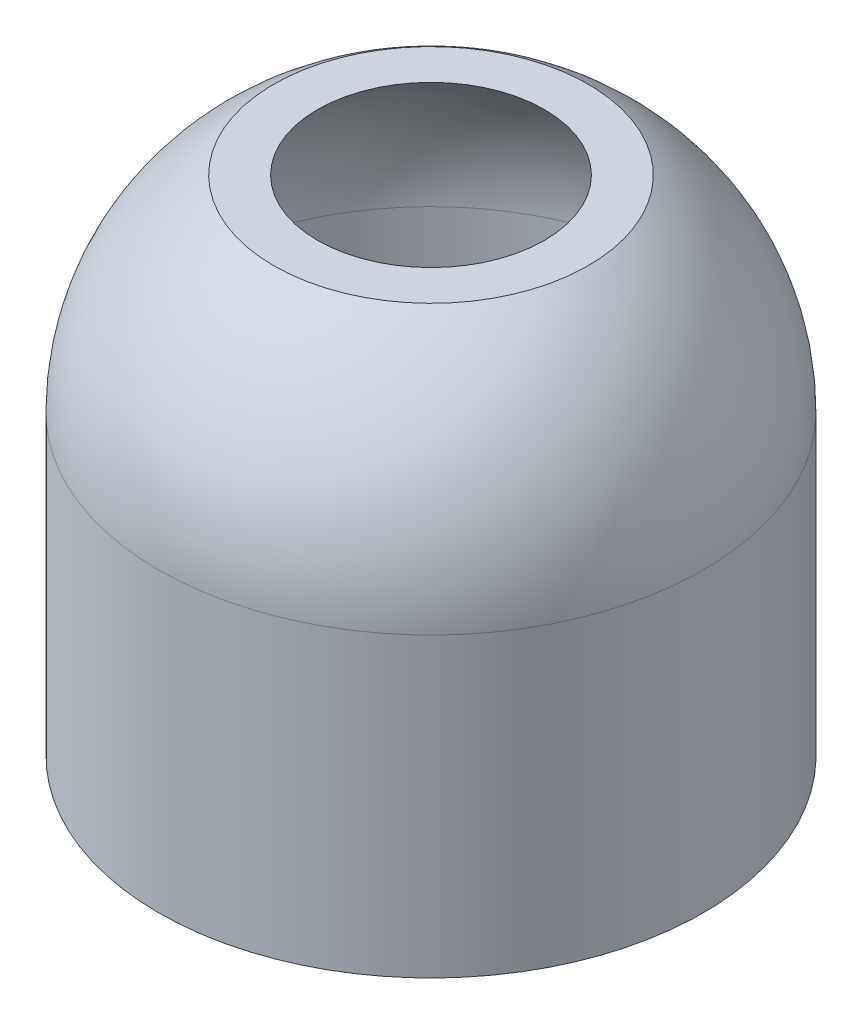
from build123d import *


with BuildPart() as part:
    # Sketch3 → Revolve1 (revolve)
    with BuildSketch(Plane.XY):
        with BuildLine():
            Line((27.5, 0), (27.5, 30))
            ThreePointArc((27.5, 30), (24.398035418, 41.912854402), (15.88, 50.8))
            Line((15.88, 50.8), (11.457943172, 50.8))
            ThreePointArc((11.457943172, 50.8), (21.660877372, 42.548101051), (25.5, 30))
            Line((25.5, 30), (25.5, 0))
            Line((25.5, 0), (27.5, 0))
        make_face()
    revolve(axis=Axis((0, 50.369897959, 0), (0, -1, 0)))


solid = part.part
